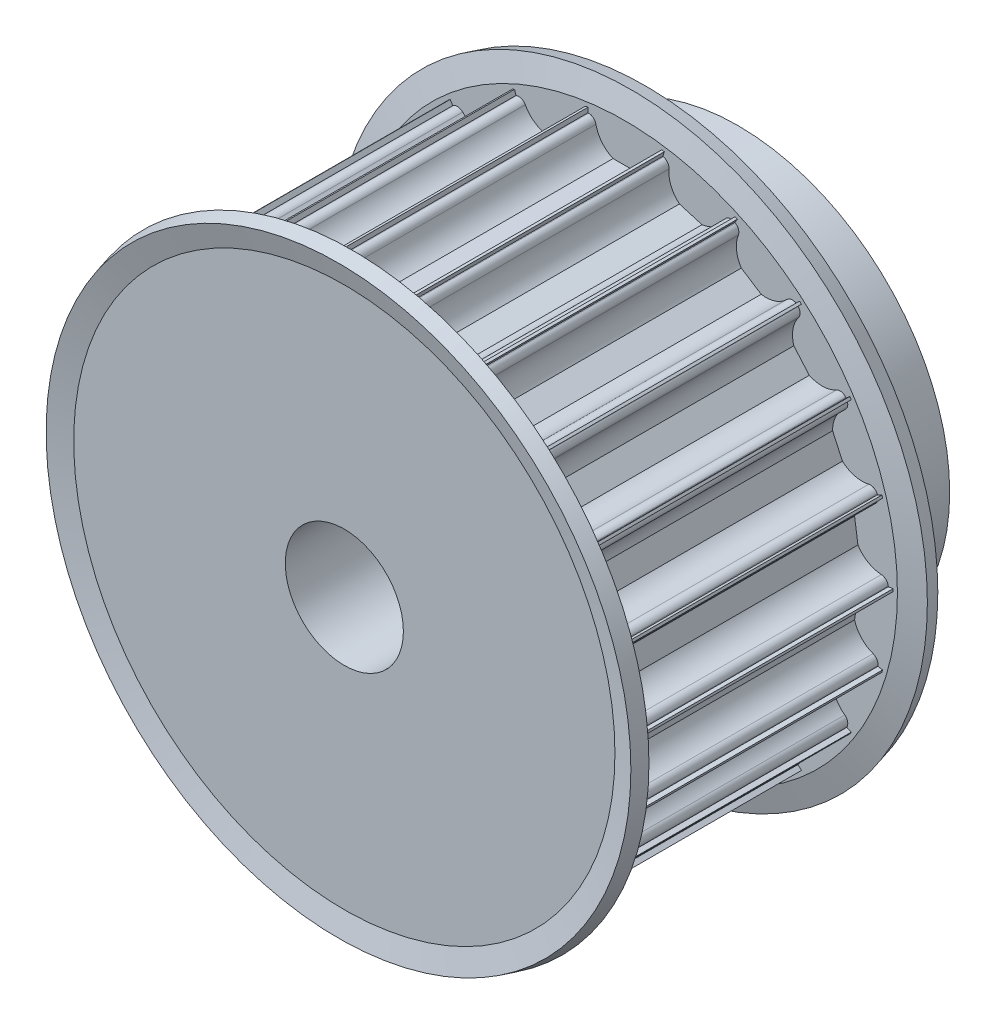
from build123d import *

# Parameters (mm, degrees)
ENL_V_MAT_EXTRU_1_DEPTH      = 41
R_P_TITION_CIRCULAIRE1_COUNT = 22


with BuildPart() as part:
    # Esquisse1 → Révolution1 (revolve)
    with BuildSketch(Plane(origin=(0, 0, 0), x_dir=(0, 0, -1), z_dir=(1, 0, 0))):
        Polygon((0, 6), (0, 27.25), (30, 27.25), (30, 21.5), (40, 21.5), (40, 6), align=None)
    revolve(axis=Axis((0, 0, 55), (0, 0, -1)))

    # Esquisse2 → Enlèv. mat.-Extru.1 (cut, through all)
    with BuildSketch(Plane.XY):
        with BuildLine():
            Line((3.674234614, 26.5), (3.75, 26.5))
            Line((3.75, 26.5), (3.75, 28.5))
            Line((3.75, 28.5), (-3.75, 28.5))
            Line((-3.75, 28.5), (-3.75, 26.5))
            Line((-3.75, 26.5), (-3.674234614, 26.5))
            ThreePointArc((-3.674234614, 26.5), (-3.199892965, 26.330947502), (-2.939387691, 25.9))
            ThreePointArc((-2.939387691, 25.9), (-2.331759211, 24.612435701), (-1.198957881, 23.75))
            Line((-1.198957881, 23.75), (1.198957881, 23.75))
            ThreePointArc((1.198957881, 23.75), (2.331759211, 24.612435701), (2.939387691, 25.9))
            ThreePointArc((2.939387691, 25.9), (3.199892965, 26.330947502), (3.674234614, 26.5))
        make_face()
    enl_v_mat_extru_1 = extrude(amount=-ENL_V_MAT_EXTRU_1_DEPTH, mode=Mode.SUBTRACT)

    # Répétition circulaire1: Enlèv. mat.-Extru.1 ×22 about axis
    r_p_tition_circulaire1_axis = Axis((0, 0, 0), (0, 0, 1))
    for i in range(1, R_P_TITION_CIRCULAIRE1_COUNT):
        add(enl_v_mat_extru_1.rotate(r_p_tition_circulaire1_axis, i * 360 / R_P_TITION_CIRCULAIRE1_COUNT), mode=Mode.SUBTRACT)

    # Esquisse3 → Révolution3 (revolve)
    with BuildSketch(Plane(origin=(0, 0, 0), x_dir=(0, 0, -1), z_dir=(1, 0, 0))):
        Polygon((0, 27.493260406), (0, 22.690739153), (1.5, 22.690739153), (1.5, 27.690739153), (0.856921938, 30.090739153), (-0.591966801, 29.702510585), align=None)
        Polygon((30.591966801, 29.702510585), (29.143078062, 30.090739153), (28.5, 27.690739153), (28.5, 22.690739153), (30, 22.690739153), (30, 27.493260406), align=None)
    revolve(axis=Axis((0, 0, 55), (0, 0, -1)))


solid = part.part
